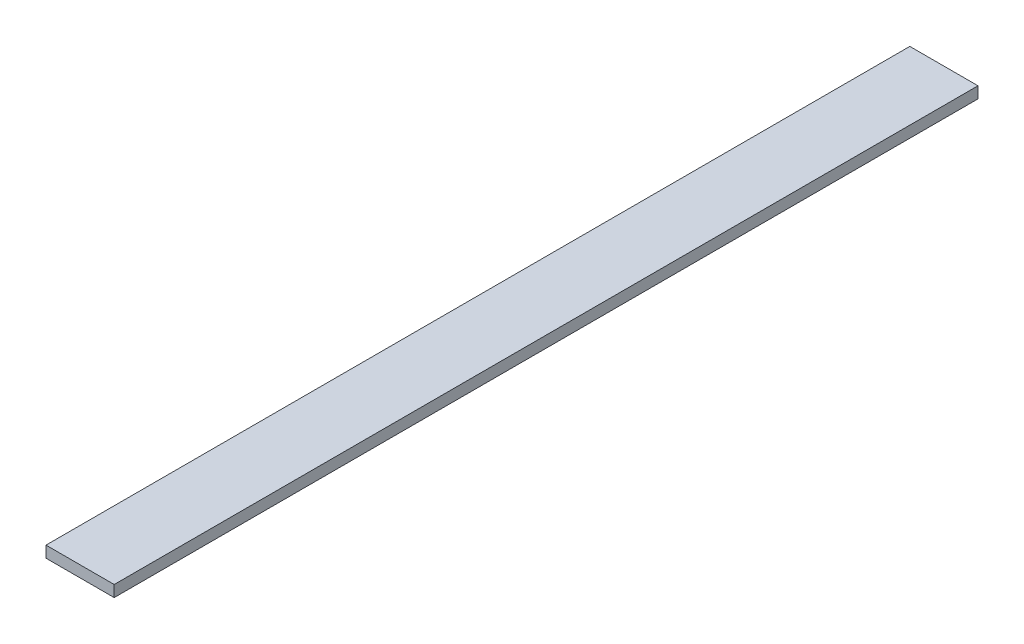
from build123d import *

# Parameters (mm, degrees)
SKETCH1_W           = 19.05
SKETCH1_H           = 3.175
BOSS_EXTRUDE1_DEPTH = 241.3


with BuildPart() as part:
    # Sketch1 → Boss-Extrude1 (new body)
    with BuildSketch(Plane.XY):
        with Locations((9.525, 1.5875)):
            Rectangle(SKETCH1_W, SKETCH1_H)
    extrude(amount=BOSS_EXTRUDE1_DEPTH)


solid = part.part
